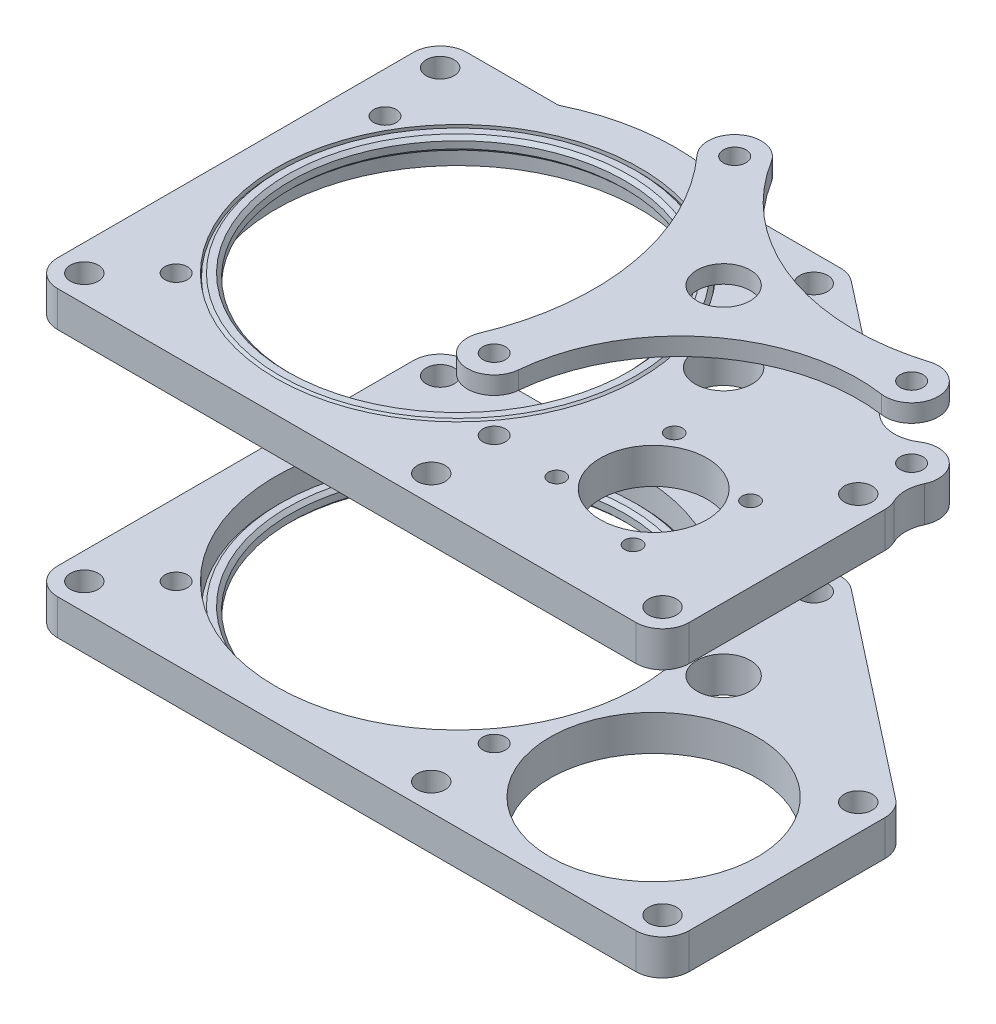
from build123d import *

# Parameters (mm, degrees)
SKETCH3_R               = 32.5
SKETCH3_R_2             = 2.4892
SKETCH3_R_3             = 18.5166
SKETCH3_R_4             = 4.7625
BOSS_EXTRUDE1_DEPTH     = 6.35
SKETCH4_R               = 2.4892
SKETCH4_R_2             = 5.08
SKETCH4_R_3             = 9.525
SKETCH4_R_4             = 32.5
SKETCH4_R_5             = 2.0193
BOSS_EXTRUDE2_DEPTH     = 6.35
SKETCH6_R               = 4.7625
SKETCH6_R_2             = 2.0193
BOSS_EXTRUDE3_DEPTH     = 3.175
SKETCH13_R              = 32.373
SKETCH13_R_2            = 29.833
BOSS_EXTRUDE7_DEPTH     = 2.525
SKETCH14_R              = 32.373
SKETCH14_R_2            = 29.833
BOSS_EXTRUDE8_DEPTH     = 2.525
SKETCH8_R               = 1.5
CUT_EXTRUDE1_DEPTH      = 54.975
SKETCH9_R               = 2.0193
CUT_EXTRUDE2_DEPTH      = 13.7
CUT_EXTRUDE2_DEPTH_BACK = 54.975
FILLET1_R               = 6.35
CHAMFER2_SIZE           = 0.635
CHAMFER1_SIZE           = 0.635


with BuildPart() as part:
    # Sketch3 → Boss-Extrude1 (new body)
    with BuildSketch(Plane(origin=(0, 27.925, 0), x_dir=(1, 0, 0), z_dir=(0, 1, 0))):
        with BuildLine():
            Line((-38.1, 30.1625), (-38.1, -33.3375))
            ThreePointArc((-38.1, -33.3375), (-36.705096045, -36.705096045), (-33.3375, -38.1))
            Line((-33.3375, -38.1), (69.85, -38.1))
            ThreePointArc((69.85, -38.1), (73.217596045, -36.705096045), (74.6125, -33.3375))
            Line((74.6125, -33.3375), (74.6125, 1.5875))
            ThreePointArc((74.6125, 1.5875), (74.131363352, 3.673485162), (72.785168096, 5.337992567))
            Line((72.785168096, 5.337992567), (36.272668096, 33.912992567))
            ThreePointArc((36.272668096, 33.912992567), (34.889866806, 34.664895313), (33.3375, 34.925))
            Line((33.3375, 34.925), (17.016664626, 34.925))
            ThreePointArc((17.016664626, 34.925), (0, 38.85), (-17.016664626, 34.925))
            Line((-17.016664626, 34.925), (-33.3375, 34.925))
            ThreePointArc((-33.3375, 34.925), (-36.705096045, 33.530096045), (-38.1, 30.1625))
        make_face()
        Circle(SKETCH3_R, mode=Mode.SUBTRACT)
        with Locations((-33.3375, 30.1625)):
            Circle(SKETCH3_R_2, mode=Mode.SUBTRACT)
        with Locations((-33.3375, -33.3375)):
            Circle(SKETCH3_R_2, mode=Mode.SUBTRACT)
        with Locations((28.575, -33.3375)):
            Circle(SKETCH3_R_2, mode=Mode.SUBTRACT)
        with Locations((50.8, -15.875)):
            Circle(SKETCH3_R_3, mode=Mode.SUBTRACT)
        with Locations((38.300729341, 9.113233891)):
            Circle(SKETCH3_R_4, mode=Mode.SUBTRACT)
        with Locations((69.85, -33.3375)):
            Circle(SKETCH3_R_2, mode=Mode.SUBTRACT)
        with Locations((69.85, 1.5875)):
            Circle(SKETCH3_R_2, mode=Mode.SUBTRACT)
        with Locations((33.3375, 30.1625)):
            Circle(SKETCH3_R_2, mode=Mode.SUBTRACT)
    extrude(amount=-BOSS_EXTRUDE1_DEPTH)


with BuildPart() as body_2:
    # Sketch4 → Boss-Extrude2 (new body)
    with BuildSketch(Plane(origin=(0, 69.2, 0), x_dir=(1, 0, 0), z_dir=(0, 1, 0))):
        with BuildLine():
            Line((65.093797073, 11.357326411), (36.272668096, 33.912992567))
            ThreePointArc((36.272668096, 33.912992567), (34.889866806, 34.664895313), (33.3375, 34.925))
            Line((33.3375, 34.925), (17.016664626, 34.925))
            ThreePointArc((17.016664626, 34.925), (0, 38.85), (-17.016664626, 34.925))
            Line((-17.016664626, 34.925), (-33.3375, 34.925))
            ThreePointArc((-33.3375, 34.925), (-36.705096045, 33.530096045), (-38.1, 30.1625))
            Line((-38.1, 30.1625), (-38.1, -33.3375))
            ThreePointArc((-38.1, -33.3375), (-36.705096045, -36.705096045), (-33.3375, -38.1))
            Line((-33.3375, -38.1), (69.85, -38.1))
            ThreePointArc((69.85, -38.1), (73.217596045, -36.705096045), (74.6125, -33.3375))
            Line((74.6125, -33.3375), (74.6125, 1.5875))
            ThreePointArc((74.6125, 1.5875), (74.131363352, 3.673485162), (72.785168096, 5.337992567))
            Line((72.785168096, 5.337992567), (71.230700901, 6.554532112))
            ThreePointArc((71.230700901, 6.554532112), (72.785168096, 14.862992567), (65.093797073, 11.357326411))
        make_face()
        with Locations((33.3375, 30.1625)):
            Circle(SKETCH4_R, mode=Mode.SUBTRACT)
        with Locations((69.85, 1.5875)):
            Circle(SKETCH4_R, mode=Mode.SUBTRACT)
        with Locations((69.85, -33.3375)):
            Circle(SKETCH4_R, mode=Mode.SUBTRACT)
        with Locations((28.575, -33.3375)):
            Circle(SKETCH4_R, mode=Mode.SUBTRACT)
        with Locations((-33.3375, -33.3375)):
            Circle(SKETCH4_R, mode=Mode.SUBTRACT)
        with Locations((-33.3375, 30.1625)):
            Circle(SKETCH4_R, mode=Mode.SUBTRACT)
        with Locations((38.300729341, 9.113233891)):
            Circle(SKETCH4_R_2, mode=Mode.SUBTRACT)
        with Locations((50.8, -15.875)):
            Circle(SKETCH4_R_3, mode=Mode.SUBTRACT)
        Circle(SKETCH4_R_4, mode=Mode.SUBTRACT)
        with Locations((19.332478919, 30.058204223)):
            Circle(SKETCH4_R_5, mode=Mode.SUBTRACT)
        with Locations((69.85, 11.1125)):
            Circle(SKETCH4_R_5, mode=Mode.SUBTRACT)
        with Locations((28.295721181, -21.830999635)):
            Circle(SKETCH4_R_5, mode=Mode.SUBTRACT)
    extrude(amount=BOSS_EXTRUDE2_DEPTH)

    # Sketch8 → Cut-Extrude1 (cut, through all)
    with BuildSketch(Plane(origin=(0, 75.55, 0), x_dir=(1, 0, 0), z_dir=(0, 1, 0))):
        with Locations((43.992012062, -5.391617901)):
            Circle(SKETCH8_R)
        with Locations((61.283382099, -9.067012062)):
            Circle(SKETCH8_R)
        with Locations((57.607987938, -26.358382099)):
            Circle(SKETCH8_R)
        with Locations((40.316617901, -22.682987938)):
            Circle(SKETCH8_R)
    extrude(amount=-CUT_EXTRUDE1_DEPTH, mode=Mode.SUBTRACT)


with BuildPart() as body_3:
    # Sketch6 → Boss-Extrude3 (new body)
    with BuildSketch(Plane(origin=(0, 85.075, 0), x_dir=(1, 0, 0), z_dir=(0, 1, 0))):
        with BuildLine():
            ThreePointArc((23.381787081, 32.565096654), (16.469460575, 33.864059213), (15.801303162, 26.862550296))
            ThreePointArc((15.801303162, 26.862550296), (26.644984318, 4.602603851), (23.897134883, -20.005117705))
            ThreePointArc((23.897134883, -20.005117705), (27.160892551, -26.456318028), (33.039902775, -22.248309176))
            ThreePointArc((33.039902775, -22.248309176), (44.943402215, -0.150432703), (69.17405827, 6.398212246))
            ThreePointArc((69.17405827, 6.398212246), (74.59793655, 11.484662284), (68.44777711, 15.663892887))
            ThreePointArc((68.44777711, 15.663892887), (43.031292771, 16.425853008), (23.381787081, 32.565096654))
        make_face()
        with Locations((38.300729341, 9.113233891)):
            Circle(SKETCH6_R, mode=Mode.SUBTRACT)
        with Locations((28.295721181, -21.830999635)):
            Circle(SKETCH6_R_2, mode=Mode.SUBTRACT)
        with Locations((69.85, 11.1125)):
            Circle(SKETCH6_R_2, mode=Mode.SUBTRACT)
        with Locations((19.332478919, 30.058204223)):
            Circle(SKETCH6_R_2, mode=Mode.SUBTRACT)
    extrude(amount=BOSS_EXTRUDE3_DEPTH)


with BuildPart() as body_4:
    # Sketch13 → Boss-Extrude7 (new body)
    with BuildSketch(Plane(origin=(0, 75.55, 0), x_dir=(1, 0, 0), z_dir=(0, 1, 0))):
        Circle(SKETCH13_R)
        Circle(SKETCH13_R_2, mode=Mode.SUBTRACT)
    extrude(amount=-BOSS_EXTRUDE7_DEPTH)

    # Chamfer1
    chamfer1_edges = [body_4.edges().sort_by_distance(p)[0] for p in [
        (-32.373, 75.55, 0),
        (-32.373, 73.025, 0),
        (-29.833, 73.025, 0),
        (-29.833, 75.55, 0),
    ]]
    chamfer(chamfer1_edges, length=CHAMFER1_SIZE)


with BuildPart() as body_5:
    # Sketch14 → Boss-Extrude8 (new body)
    with BuildSketch(Plane.XZ.offset(-21.575)):
        Circle(SKETCH14_R)
        Circle(SKETCH14_R_2, mode=Mode.SUBTRACT)
    extrude(amount=-BOSS_EXTRUDE8_DEPTH)

    # Chamfer2
    chamfer2_edges = [body_5.edges().sort_by_distance(p)[0] for p in [
        (-32.373, 21.575, 0),
        (-32.373, 24.1, 0),
        (-29.833, 24.1, 0),
        (-29.833, 21.575, 0),
    ]]
    chamfer(chamfer2_edges, length=CHAMFER2_SIZE)


with BuildPart() as cut_extrude2_tool:
    # Sketch9 → Cut-Extrude2 (new body, two sides)
    with BuildSketch(Plane(origin=(0, 75.55, 0), x_dir=(1, 0, 0), z_dir=(0, 1, 0))) as cut_extrude2_sk:
        with Locations((-25.145212114, -25.145212114)):
            Circle(SKETCH9_R)
        with Locations((-30.796469576, 17.78035)):
            Circle(SKETCH9_R)
        with Locations((19.332478919, 30.058204223)):
            Circle(SKETCH9_R)
        with Locations((28.295721181, -21.830999635)):
            Circle(SKETCH9_R)
    extrude(amount=CUT_EXTRUDE2_DEPTH)
    extrude(cut_extrude2_sk.sketch, amount=-CUT_EXTRUDE2_DEPTH_BACK)


with BuildPart() as part_1:
    add(part.part)

    # Cut-Extrude2: cut by cut_extrude2_tool
    add(cut_extrude2_tool.part, mode=Mode.SUBTRACT)


with BuildPart() as body_2_1:
    add(body_2.part)

    # Cut-Extrude2: cut by cut_extrude2_tool
    add(cut_extrude2_tool.part, mode=Mode.SUBTRACT)

    # Fillet1
    fillet1_edges = [body_2_1.edges().sort_by_distance(p)[0] for p in [
        (65.093797073, 72.375, -11.357326411),
        (71.230700901, 72.375, -6.554532112),
    ]]
    fillet(fillet1_edges, radius=FILLET1_R)


solid = Compound([body_3.part, body_4.part, body_5.part, part_1.part, body_2_1.part])
